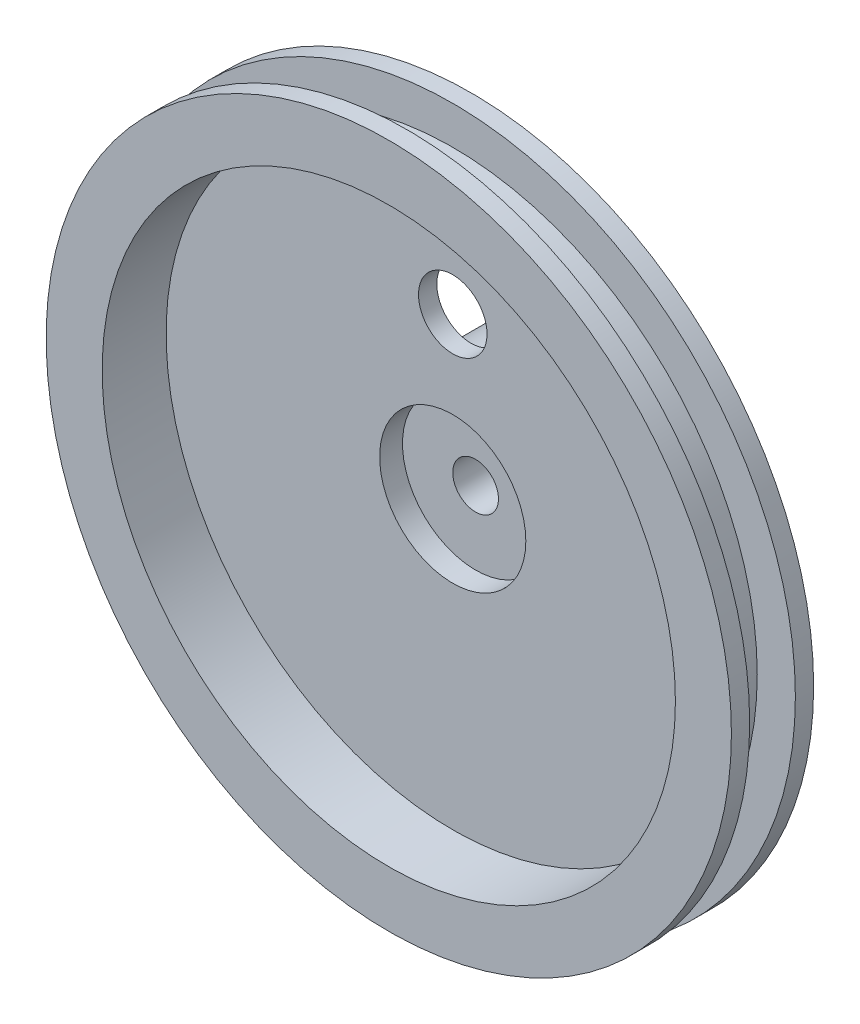
from build123d import *

# Parameters (mm, degrees)
SKETCH3_R           = 10.16
CUT_EXTRUDE1_DEPTH  = 2.54
SKETCH5_R           = 4.7625
CUT_EXTRUDE2_DEPTH  = 6.35
SKETCH6_R           = 13.335
SKETCH6_R_2         = 9.525
BOSS_EXTRUDE1_DEPTH = 6.35
SKETCH7_R           = 1.27
CUT_EXTRUDE3_DEPTH  = 25.4
CUT_EXTRUDE4_DEPTH  = 6.35
CUT_EXTRUDE5_DEPTH  = 2.54
SKETCH11_R          = 0.889
CUT_EXTRUDE6_DEPTH  = 55.372


with BuildPart() as part:
    # Sketch2 → Revolve1 (revolve)
    with BuildSketch(Plane(origin=(0, 0, 0), x_dir=(0, 0, -1), z_dir=(1, 0, 0))):
        Polygon((-6.35, 42.32529), (0, 42.32529), (0, 47.625), (2.54, 47.625), (2.54, 0), (0, 0), (0, 39.839805153), (-8.89, 39.839805153), (-8.89, 47.625), (-6.35, 47.625), align=None)
    revolve(axis=Axis((0, 0, 0), (0, 0, -1)))

    # Sketch3 → Cut-Extrude1 (cut)
    with BuildSketch(Plane.XY):
        Circle(SKETCH3_R)
    extrude(amount=-CUT_EXTRUDE1_DEPTH, mode=Mode.SUBTRACT)

    # Sketch4 → Revolve2 (revolve)
    with BuildSketch(Plane(origin=(0, 0, 0), x_dir=(1, 0, 0), z_dir=(0, 1, 0))):
        Polygon((0, 14.2494), (-3.175, 14.2494), (-3.175, 3.175), (-10.16, 3.175), (-10.16, 0), (-13.335, 0), (-13.335, 15.2019), (0, 15.2019), align=None)
    revolve(axis=Axis((0, 0, 0), (0, 0, -1)))

    # Sketch5 → Cut-Extrude2 (cut)
    with BuildSketch(Plane.XY):
        with Locations((0, 22.225)):
            Circle(SKETCH5_R)
    extrude(amount=-CUT_EXTRUDE2_DEPTH, mode=Mode.SUBTRACT)

    # Sketch6 → Boss-Extrude1 (add)
    with BuildSketch(Plane(origin=(0, 0, -15.2019), x_dir=(-1, 0, 0), z_dir=(0, 0, -1))):
        Circle(SKETCH6_R)
        Circle(SKETCH6_R_2, mode=Mode.SUBTRACT)
    extrude(amount=BOSS_EXTRUDE1_DEPTH)

    # Sketch7 → Cut-Extrude3 (cut)
    with BuildSketch(Plane(origin=(0, 0, 0), x_dir=(0, 0, -1), z_dir=(1, 0, 0))):
        with Locations((8.962319715, 0)):
            Circle(SKETCH7_R)
    extrude(amount=-CUT_EXTRUDE3_DEPTH, mode=Mode.SUBTRACT)

    # Sketch8 → Cut-Extrude4 (cut)
    with BuildSketch(Plane(origin=(0, 0, -21.5519), x_dir=(-1, 0, 0), z_dir=(0, 0, -1))):
        with BuildLine():
            Line((2.725322184, 6.579509779), (5.964417729, 14.399378174))
            ThreePointArc((5.964417729, 14.399378174), (0, 15.585774625), (-5.964417729, 14.399378174))
            Line((-5.964417729, 14.399378174), (-2.725322184, 6.579509779))
            ThreePointArc((-2.725322184, 6.579509779), (0, 7.121610066), (2.725322184, 6.579509779))
        make_face()
    extrude(amount=-CUT_EXTRUDE4_DEPTH, mode=Mode.SUBTRACT)

    # Sketch10 → Cut-Extrude5 (cut)
    with BuildSketch(Plane(origin=(0, 0, -19.0119), x_dir=(-1, 0, 0), z_dir=(0, 0, -1))):
        with BuildLine():
            Line((6.29135007, 1.685762171), (16.396038566, 4.393305293))
            ThreePointArc((16.396038566, 4.393305293), (14.700286019, 8.48721409), (12.002733273, 12.002733273))
            Line((12.002733273, 12.002733273), (4.6055879, 4.6055879))
            ThreePointArc((4.6055879, 4.6055879), (5.64067016, 3.256642435), (6.29135007, 1.685762171))
        make_face()
        with BuildLine():
            Line((-4.6055879, 4.6055879), (-12.002733273, 12.002733273))
            ThreePointArc((-12.002733273, 12.002733273), (-14.700286019, 8.48721409), (-16.396038566, 4.393305293))
            Line((-16.396038566, 4.393305293), (-6.29135007, 1.685762171))
            ThreePointArc((-6.29135007, 1.685762171), (-5.64067016, 3.256642435), (-4.6055879, 4.6055879))
        make_face()
    extrude(amount=-CUT_EXTRUDE5_DEPTH, mode=Mode.SUBTRACT)

    # Sketch11 → Cut-Extrude6 (cut)
    with BuildSketch(Plane(origin=(0, 0, 0), x_dir=(1, 0, 0), z_dir=(0, 1, 0))):
        with Locations((0, -3.870418615)):
            Circle(SKETCH11_R)
    extrude(amount=CUT_EXTRUDE6_DEPTH, mode=Mode.SUBTRACT)


solid = part.part
